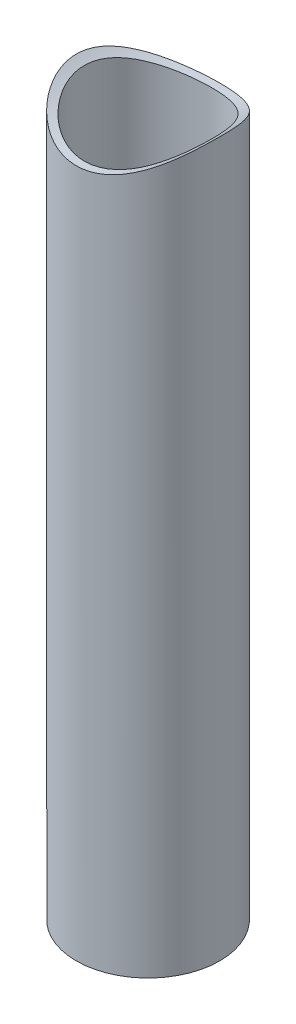
from build123d import *

# Parameters (mm, degrees)
SKETCH1_R               = 7.9375
SKETCH1_R_2             = 7.0485
BOSS_EXTRUDE1_DEPTH     = 88.9
SKETCH2_R               = 12.7
CUT_EXTRUDE1_DEPTH      = 8.9375
CUT_EXTRUDE1_DEPTH_BACK = 8.9375


with BuildPart() as part:
    # Sketch1 → Boss-Extrude1 (new body)
    with BuildSketch(Plane(origin=(0, 0, 0), x_dir=(1, 0, 0), z_dir=(0, 1, 0))):
        Circle(SKETCH1_R)
        Circle(SKETCH1_R_2, mode=Mode.SUBTRACT)
    extrude(amount=BOSS_EXTRUDE1_DEPTH)

    # Sketch2 → Cut-Extrude1 (cut, two sides)
    with BuildSketch(Plane.XY) as cut_extrude1_sk:
        with Locations((0, 88.9)):
            Circle(SKETCH2_R)
    extrude(amount=CUT_EXTRUDE1_DEPTH, mode=Mode.SUBTRACT)
    extrude(cut_extrude1_sk.sketch, amount=-CUT_EXTRUDE1_DEPTH_BACK, mode=Mode.SUBTRACT)


solid = part.part
